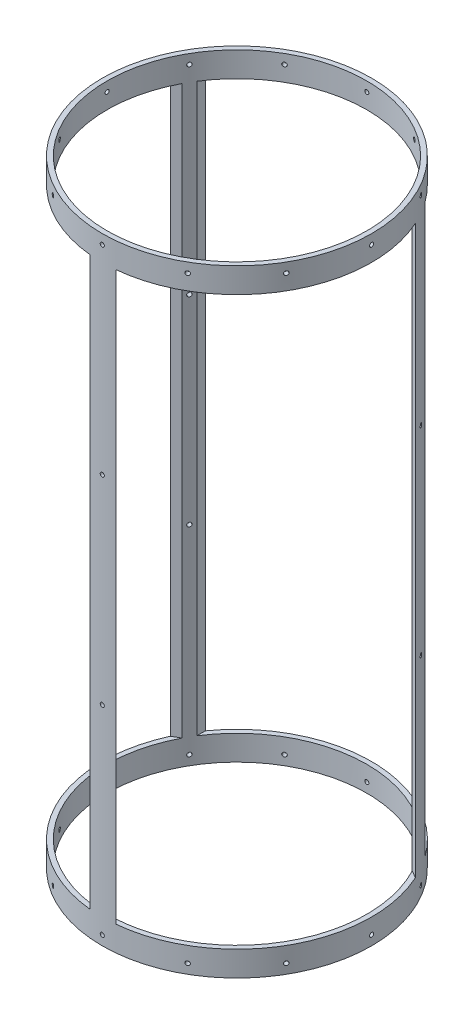
from build123d import *

# Parameters (mm, degrees)
SKETCH1_R                = 88.9
SKETCH1_R_2              = 85.725
BOSS_EXTRUDE1_DEPTH      = 203.581
CUT_EXTRUDE1_START       = -88.9
SKETCH2_W                = 144.78
SKETCH2_H                = 374.142
CUT_EXTRUDE1_DEPTH       = 42.981991
CIRPATTERN1_COUNT        = 3
SKETCH4_R                = 1.35255
CUT_EXTRUDE3_DEPTH       = 15.24
CIRPATTERN3_COUNT        = 12
MIRROR1_COPY_1_SKETCH_R  = 1.35255
MIRROR1_COPY_1_DEPTH     = 15.24
MIRROR1_COPY_2_SKETCH_R  = 1.35255
MIRROR1_COPY_2_DEPTH     = 15.24
MIRROR1_COPY_3_SKETCH_R  = 1.35255
MIRROR1_COPY_3_DEPTH     = 15.24
MIRROR1_COPY_4_SKETCH_R  = 1.35255
MIRROR1_COPY_4_DEPTH     = 15.24
MIRROR1_COPY_5_SKETCH_R  = 1.35255
MIRROR1_COPY_5_DEPTH     = 15.24
MIRROR1_COPY_6_SKETCH_R  = 1.35255
MIRROR1_COPY_6_DEPTH     = 15.24
MIRROR1_COPY_7_SKETCH_R  = 1.35255
MIRROR1_COPY_7_DEPTH     = 15.24
MIRROR1_COPY_8_SKETCH_R  = 1.35255
MIRROR1_COPY_8_DEPTH     = 15.24
MIRROR1_COPY_9_SKETCH_R  = 1.35255
MIRROR1_COPY_9_DEPTH     = 15.24
MIRROR1_COPY_10_SKETCH_R = 1.35255
MIRROR1_COPY_10_DEPTH    = 15.24
MIRROR1_COPY_11_SKETCH_R = 1.35255
MIRROR1_COPY_11_DEPTH    = 15.24
SKETCH5_R                = 1.35255
CUT_EXTRUDE4_DEPTH       = 46.482
CIRPATTERN4_COUNT        = 3


with BuildPart() as part:
    # Sketch1 → Boss-Extrude1 (new body, symmetric)
    with BuildSketch(Plane(origin=(0, 0, 0), x_dir=(1, 0, 0), z_dir=(0, 1, 0))):
        Circle(SKETCH1_R)
        Circle(SKETCH1_R_2, mode=Mode.SUBTRACT)
    extrude(amount=BOSS_EXTRUDE1_DEPTH, both=True)

    # Sketch2 → Cut-Extrude1 (cut)
    with BuildSketch(Plane.XY.offset(CUT_EXTRUDE1_START)):
        Rectangle(SKETCH2_W, SKETCH2_H)
    cut_extrude1 = extrude(amount=CUT_EXTRUDE1_DEPTH, mode=Mode.SUBTRACT)

    # CirPattern1: Cut-Extrude1 ×3 about axis
    cirpattern1_axis = Axis((0, 0, 0), (0, 1, 0))
    for i in range(1, CIRPATTERN1_COUNT):
        add(cut_extrude1.rotate(cirpattern1_axis, i * 360 / CIRPATTERN1_COUNT), mode=Mode.SUBTRACT)

    # Sketch4 → Cut-Extrude3 (cut)
    with BuildSketch(Plane(origin=(88.9, 0, 0), x_dir=(0, 0, -1), z_dir=(1, 0, 0))):
        with Locations((0, 197.231)):
            Circle(SKETCH4_R)
    cut_extrude3 = extrude(amount=-CUT_EXTRUDE3_DEPTH, mode=Mode.SUBTRACT)

    # CirPattern3: Cut-Extrude3 ×12 about axis
    cirpattern3_axis = Axis((0, 203.581, 0), (0, -1, 0))
    for i in range(1, CIRPATTERN3_COUNT):
        add(cut_extrude3.rotate(cirpattern3_axis, i * 360 / CIRPATTERN3_COUNT), mode=Mode.SUBTRACT)

    # Mirror1: Cut-Extrude3 across plane
    add(cut_extrude3.mirror(Plane.ZX), mode=Mode.SUBTRACT)

    # Mirror1 copy 1 sketch → Mirror1 copy 1 (cut)
    with BuildSketch(Plane(origin=(76.989658396, 0, 44.45), x_dir=(0.5, 0, -0.866025404), z_dir=(0.866025404, 0, 0.5))):
        with Locations((0, -197.231)):
            Circle(MIRROR1_COPY_1_SKETCH_R)
    extrude(amount=-MIRROR1_COPY_1_DEPTH, mode=Mode.SUBTRACT)

    # Mirror1 copy 2 sketch → Mirror1 copy 2 (cut)
    with BuildSketch(Plane(origin=(44.45, 0, 76.989658396), x_dir=(0.866025404, 0, -0.5), z_dir=(0.5, 0, 0.866025404))):
        with Locations((0, -197.231)):
            Circle(MIRROR1_COPY_2_SKETCH_R)
    extrude(amount=-MIRROR1_COPY_2_DEPTH, mode=Mode.SUBTRACT)

    # Mirror1 copy 3 sketch → Mirror1 copy 3 (cut)
    with BuildSketch(Plane.XY.offset(88.9)):
        with Locations((0, -197.231)):
            Circle(MIRROR1_COPY_3_SKETCH_R)
    extrude(amount=-MIRROR1_COPY_3_DEPTH, mode=Mode.SUBTRACT)

    # Mirror1 copy 4 sketch → Mirror1 copy 4 (cut)
    with BuildSketch(Plane(origin=(-44.45, 0, 76.989658396), x_dir=(0.866025404, 0, 0.5), z_dir=(-0.5, 0, 0.866025404))):
        with Locations((0, -197.231)):
            Circle(MIRROR1_COPY_4_SKETCH_R)
    extrude(amount=-MIRROR1_COPY_4_DEPTH, mode=Mode.SUBTRACT)

    # Mirror1 copy 5 sketch → Mirror1 copy 5 (cut)
    with BuildSketch(Plane(origin=(-76.989658396, 0, 44.45), x_dir=(0.5, 0, 0.866025404), z_dir=(-0.866025404, 0, 0.5))):
        with Locations((0, -197.231)):
            Circle(MIRROR1_COPY_5_SKETCH_R)
    extrude(amount=-MIRROR1_COPY_5_DEPTH, mode=Mode.SUBTRACT)

    # Mirror1 copy 6 sketch → Mirror1 copy 6 (cut)
    with BuildSketch(Plane.ZY.offset(88.9)):
        with Locations((0, -197.231)):
            Circle(MIRROR1_COPY_6_SKETCH_R)
    extrude(amount=-MIRROR1_COPY_6_DEPTH, mode=Mode.SUBTRACT)

    # Mirror1 copy 7 sketch → Mirror1 copy 7 (cut)
    with BuildSketch(Plane(origin=(-76.989658396, 0, -44.45), x_dir=(-0.5, 0, 0.866025404), z_dir=(-0.866025404, 0, -0.5))):
        with Locations((0, -197.231)):
            Circle(MIRROR1_COPY_7_SKETCH_R)
    extrude(amount=-MIRROR1_COPY_7_DEPTH, mode=Mode.SUBTRACT)

    # Mirror1 copy 8 sketch → Mirror1 copy 8 (cut)
    with BuildSketch(Plane(origin=(-44.45, 0, -76.989658396), x_dir=(-0.866025404, 0, 0.5), z_dir=(-0.5, 0, -0.866025404))):
        with Locations((0, -197.231)):
            Circle(MIRROR1_COPY_8_SKETCH_R)
    extrude(amount=-MIRROR1_COPY_8_DEPTH, mode=Mode.SUBTRACT)

    # Mirror1 copy 9 sketch → Mirror1 copy 9 (cut)
    with BuildSketch(Plane(origin=(0, 0, -88.9), x_dir=(-1, 0, 0), z_dir=(0, 0, -1))):
        with Locations((0, -197.231)):
            Circle(MIRROR1_COPY_9_SKETCH_R)
    extrude(amount=-MIRROR1_COPY_9_DEPTH, mode=Mode.SUBTRACT)

    # Mirror1 copy 10 sketch → Mirror1 copy 10 (cut)
    with BuildSketch(Plane(origin=(44.45, 0, -76.989658396), x_dir=(-0.866025404, 0, -0.5), z_dir=(0.5, 0, -0.866025404))):
        with Locations((0, -197.231)):
            Circle(MIRROR1_COPY_10_SKETCH_R)
    extrude(amount=-MIRROR1_COPY_10_DEPTH, mode=Mode.SUBTRACT)

    # Mirror1 copy 11 sketch → Mirror1 copy 11 (cut)
    with BuildSketch(Plane(origin=(76.989658396, 0, -44.45), x_dir=(-0.5, 0, -0.866025404), z_dir=(0.866025404, 0, -0.5))):
        with Locations((0, -197.231)):
            Circle(MIRROR1_COPY_11_SKETCH_R)
    extrude(amount=-MIRROR1_COPY_11_DEPTH, mode=Mode.SUBTRACT)

    # Sketch5 → Cut-Extrude4 (cut)
    with BuildSketch(Plane.XY.offset(88.9)):
        with Locations((0, -65.7606)):
            Circle(SKETCH5_R)
        with Locations((0, 65.7606)):
            Circle(SKETCH5_R)
    cut_extrude4 = extrude(amount=-CUT_EXTRUDE4_DEPTH, mode=Mode.SUBTRACT)

    # CirPattern4: Cut-Extrude4 ×3 about axis
    cirpattern4_axis = Axis((0, 203.581, 0), (0, -1, 0))
    for i in range(1, CIRPATTERN4_COUNT):
        add(cut_extrude4.rotate(cirpattern4_axis, i * 360 / CIRPATTERN4_COUNT), mode=Mode.SUBTRACT)


solid = part.part
